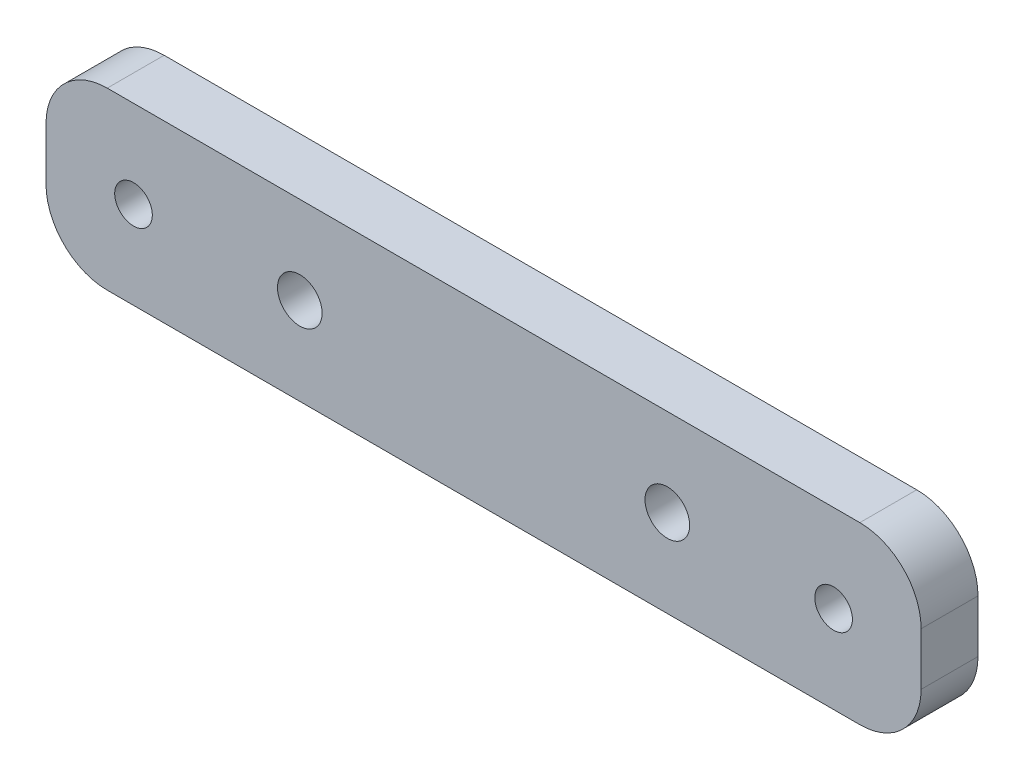
from build123d import *

# Parameters (mm, degrees)
SKETCH1_W           = 100
SKETCH1_H           = 20
SKETCH1_R           = 2.15
SKETCH1_R_2         = 2.55
BOSS_EXTRUDE1_DEPTH = 6.5
FILLET1_R           = 7


with BuildPart() as part:
    # Sketch1 → Boss-Extrude1 (new body)
    with BuildSketch(Plane.XY):
        with Locations((50, -10)):
            Rectangle(SKETCH1_W, SKETCH1_H)
        with Locations((10, -10)):
            Circle(SKETCH1_R, mode=Mode.SUBTRACT)
        with Locations((90, -10)):
            Circle(SKETCH1_R, mode=Mode.SUBTRACT)
        with Locations((29, -10)):
            Circle(SKETCH1_R_2, mode=Mode.SUBTRACT)
        with Locations((71, -10)):
            Circle(SKETCH1_R_2, mode=Mode.SUBTRACT)
    extrude(amount=BOSS_EXTRUDE1_DEPTH)

    # Fillet1
    fillet1_edges = [part.edges().sort_by_distance(p)[0] for p in [
        (0, 0, 3.25),
        (100, 0, 3.25),
        (100, -20, 3.25),
        (0, -20, 3.25),
    ]]
    fillet(fillet1_edges, radius=FILLET1_R)


solid = part.part
